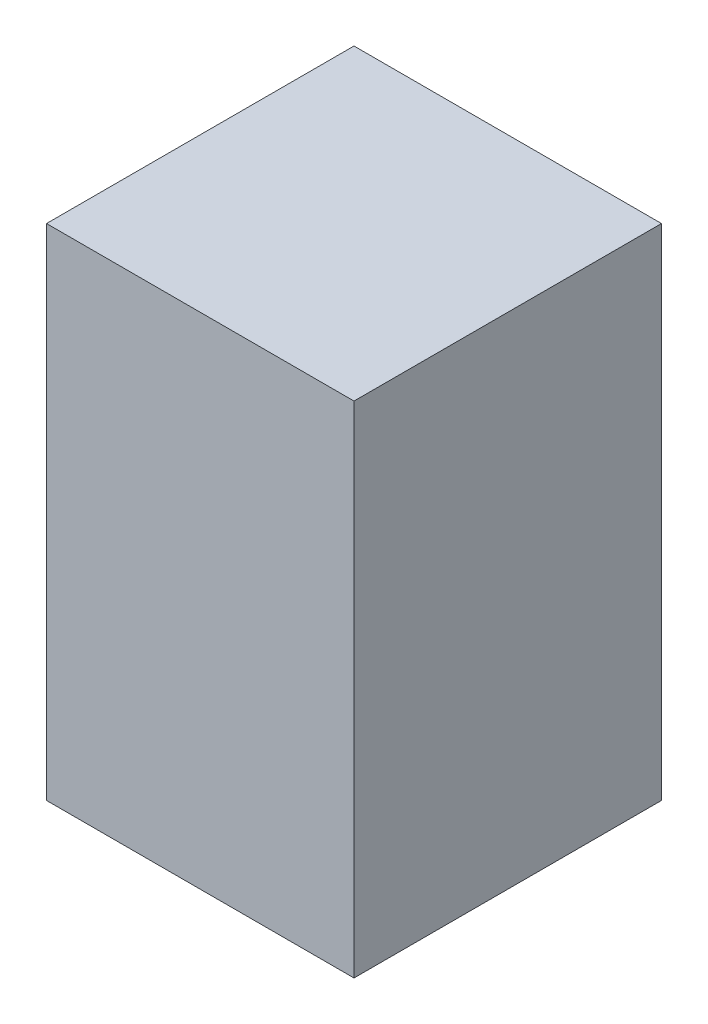
from build123d import *

# Parameters (mm, degrees)
SKETCH1_W           = 406.4
SKETCH1_H           = 406.4
BOSS_EXTRUDE1_DEPTH = 660.4


with BuildPart() as part:
    # Sketch1 → Boss-Extrude1 (new body)
    with BuildSketch(Plane(origin=(0, 0, 0), x_dir=(1, 0, 0), z_dir=(0, 1, 0))):
        with Locations((166.743803988, 148.881732046)):
            Rectangle(SKETCH1_W, SKETCH1_H)
    extrude(amount=BOSS_EXTRUDE1_DEPTH)


solid = part.part
